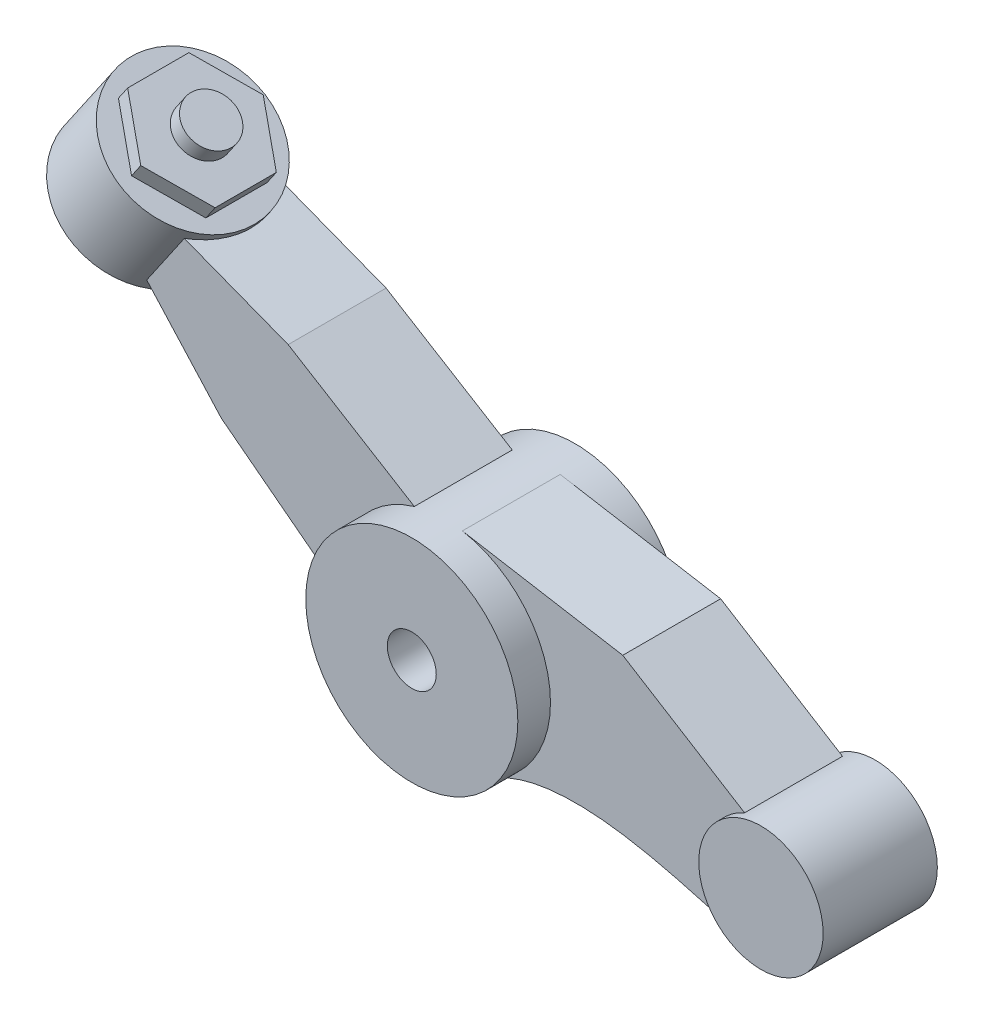
from build123d import *

# Parameters (mm, degrees)
SKETCH1_R           = 0.3
BOSS_EXTRUDE1_DEPTH = 1
BOSS_EXTRUDE2_DEPTH = 0.7
BOSS_EXTRUDE3_DEPTH = 0.6
BOSS_EXTRUDE4_DEPTH = 0.2
SKETCH5_R           = 0.3
BOSS_EXTRUDE5_DEPTH = 0.2


with BuildPart() as part:
    # Sketch1 → Boss-Extrude1 (new, symmetric)
    with BuildSketch(Plane.XY):
        with BuildLine():
            ThreePointArc((1.3, 0), (0.993808417, 0.838060159), (0.219469493, 1.281340369))
            ThreePointArc((0.219469493, 1.281340369), (-0.076650989, 1.297738273), (-0.368782161, 1.24659525))
            ThreePointArc((-0.368782161, 1.24659525), (-1.071749439, 0.735767042), (-1.295848634, -0.103809043))
            ThreePointArc((-1.295848634, -0.103809043), (-0.608256692, -1.148922885), (0.642618962, -1.13006233))
            ThreePointArc((0.642618962, -1.13006233), (1.123700283, -0.653680101), (1.3, 0))
        make_face()
        Circle(SKETCH1_R, mode=Mode.SUBTRACT)
    extrude(amount=BOSS_EXTRUDE1_DEPTH, both=True)



with BuildPart() as body_2:
    # Sketch1_3 → Boss-Extrude2 (new, symmetric)
    with BuildSketch(Plane.XY):
        with BuildLine():
            ThreePointArc((4.7425, -0.682), (4.399845934, -0.045497336), (3.679849137, 0.018939162))
            ThreePointArc((3.679849137, 0.018939162), (3.22524382, -0.573605538), (3.494717907, -1.270139049))
            ThreePointArc((3.494717907, -1.270139049), (4.30509895, -1.371722352), (4.7425, -0.682))
        make_face()
    extrude(amount=BOSS_EXTRUDE2_DEPTH, both=True)


with BuildPart() as part_1:
    add(part.part)

    add(body_2.part)  # Boss-Extrude3 merges body 2
    # Sketch1_4 → Boss-Extrude3 (add, symmetric)
    with BuildSketch(Plane.XY):
        with BuildLine():
            Line((2.186048651, 0.944502367), (0.219469493, 1.281340369))
            ThreePointArc((0.219469493, 1.281340369), (1.280435422, 0.224688962), (0.642618962, -1.13006233))
            add(Edge.make_bspline(
                [(3.494717907, -1.270139049), (2.819202825, -1.086203937), (1.830443771, -0.782374183), (0.874191176, -0.998376943), (0.642618962, -1.13006233)],
                knots=[0, 0, 0, 0, 0.738093499, 1, 1, 1, 1], degree=3))
            ThreePointArc((3.494717907, -1.270139049), (3.22524382, -0.573605538), (3.679849137, 0.018939162))
            Line((3.679849137, 0.018939162), (2.186048651, 0.944502367))
        make_face()
        with BuildLine():
            ThreePointArc((-1.295848634, -0.103809043), (-1.071749439, 0.735767042), (-0.368782161, 1.24659525))
            Line((-0.368782161, 1.24659525), (-1.915411787, 2.192219906))
            Line((-1.915411787, 2.192219906), (-3.469420101, 2.791170079))
            Line((-3.469420101, 2.791170079), (-3.851452989, 2.234684794))
            Line((-3.851452989, 2.234684794), (-2.734084179, 0.999707022))
            Line((-2.734084179, 0.999707022), (-1.295848634, -0.103809043))
        make_face()
    extrude(amount=BOSS_EXTRUDE3_DEPTH, both=True)



with BuildPart() as body_2_2:
    # Sketch2 → Revolve1 (revolve)
    with BuildSketch(Plane.XY):
        with BuildLine():
            Line((-3.851452989, 2.234684794), (-3.443951242, 2.828269098))
            Line((-3.443951242, 2.828269098), (-3.769598187, 3.051829084))
            Line((-3.769598187, 3.051829084), (-4.833144721, 1.502622153))
            ThreePointArc((-4.833144721, 1.502622153), (-4.424469448, 1.511609143), (-4.303041686, 1.901931501))
            Line((-4.303041686, 1.901931501), (-3.851452989, 2.234684794))
        make_face()
    revolve(axis=Axis((-3.769598187, 3.051829084, 0), (-0.565974647839503, -0.8244226452511785, 0)))


with BuildPart() as part_2:
    add(part_1.part)

    add(body_2_2.part)  # Revolve2 merges body 2 2
    # Sketch3 → Revolve2 (revolve)
    with BuildSketch(Plane.XY):
        Polygon((-4.2939678, 2.288010094), (-3.684979079, 3.175088861), (-4.437676954, 3.691823714), (-5.046665676, 2.804744948), align=None)
    revolve(axis=Axis((-4.2939678, 2.288010094, 0), (0.5659746478395024, 0.824422645251179, 0)))

    # Sketch4 → Boss-Extrude4 (add, symmetric)
    with BuildSketch(Plane(origin=(0.30110441, 0.438601438, 0), x_dir=(0.8244226452511789, -0.5659746478395025, 0), z_dir=(0.5659746478395025, 0.8244226452511789, 0))):
        Polygon((-4.185, 0.375277675), (-4.835, 0.75055535), (-5.485, 0.375277675), (-5.485, -0.375277675), (-4.835, -0.75055535), (-4.185, -0.375277675), align=None)
    extrude(amount=BOSS_EXTRUDE4_DEPTH, both=True)

    # Sketch5 → Boss-Extrude5 (add, symmetric)
    with BuildSketch(Plane(origin=(0.41429934, 0.603485967, 0), x_dir=(0.8244226452511786, -0.5659746478395029, 0), z_dir=(0.5659746478395029, 0.8244226452511786, 0))):
        with Locations((-4.835, 0)):
            Circle(SKETCH5_R)
    extrude(amount=BOSS_EXTRUDE5_DEPTH, both=True)


solid = part_2.part
